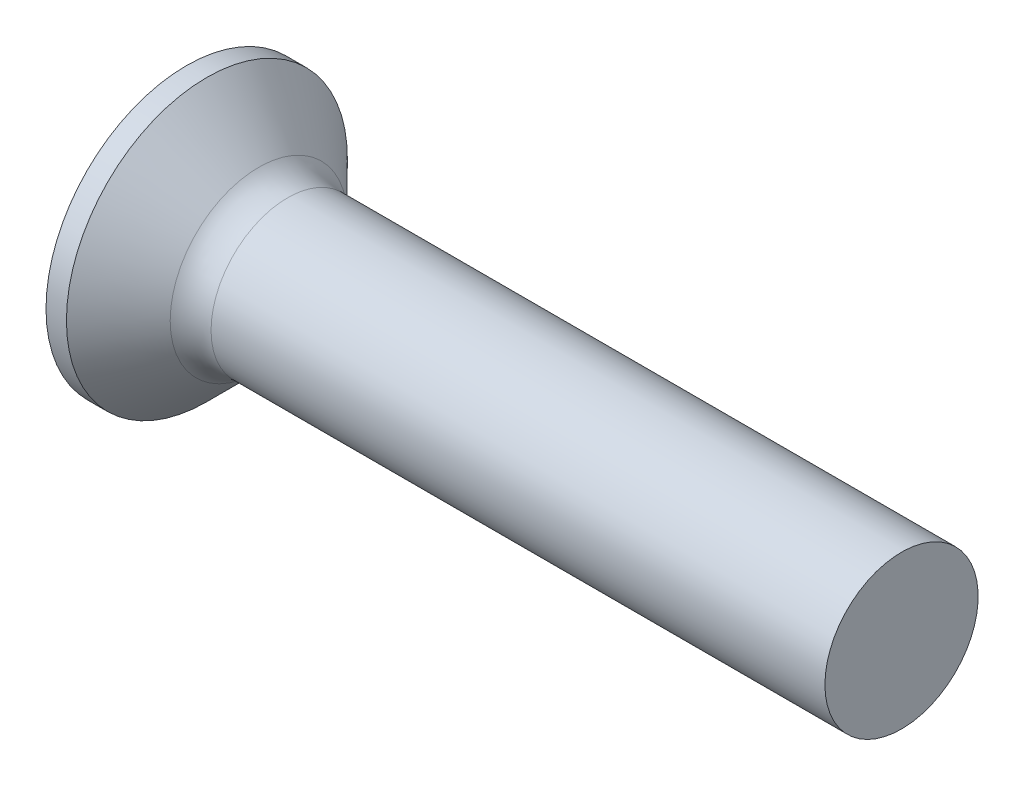
from build123d import *

# Parameters (mm, degrees)
FILLET1_R    = 0.8
SKETCH3_W    = 0.74
SKETCH3_H    = 3
SKETCH4_W    = 0.74
SKETCH4_H    = 0.99570227
RECPAT_COUNT = 2
RECPAT_ANGLE = 90


with BuildPart() as part:
    # BodySke → Base-Revolve (revolve)
    with BuildSketch(Plane.XY):
        Polygon((0, 0), (0, 2.75), (0.4, 2.75), (1.65, 1.5), (14, 1.5), (14, 0), align=None)
    revolve(axis=Axis((-6.35, 0, 0), (1, 0, 0)))

    # Fillet1
    fillet1_edges = [part.edges().sort_by_distance(p)[0] for p in [
        (1.65, -1.5, 0),
    ]]
    fillet(fillet1_edges, radius=FILLET1_R)

    # Sketch3 → Recess section 0
    with BuildSketch(Plane.ZY):
        Rectangle(SKETCH3_W, SKETCH3_H)
    # Sketch4 → Recess section 1
    with BuildSketch(Plane.ZY.offset(-2.01)):
        Rectangle(SKETCH4_W, SKETCH4_H)
    recess = loft(mode=Mode.SUBTRACT)

    # RecPat: Recess ×2 about axis
    recpat_axis = Axis((0, 0, 0), (1, 0, 0))
    for i in range(1, RECPAT_COUNT):
        add(recess.rotate(recpat_axis, i * RECPAT_ANGLE / (RECPAT_COUNT - 1)), mode=Mode.SUBTRACT)

    # RecCorSke → RecessCore (revolve, cut)
    with BuildSketch(Plane.XY):
        Polygon((0, 0), (0, 0.696552892), (2.01, 0.556), (2.190655351, 0), align=None)
    revolve(axis=Axis((-3.175, 0, 0), (1, 0, 0)), mode=Mode.SUBTRACT)


solid = part.part
